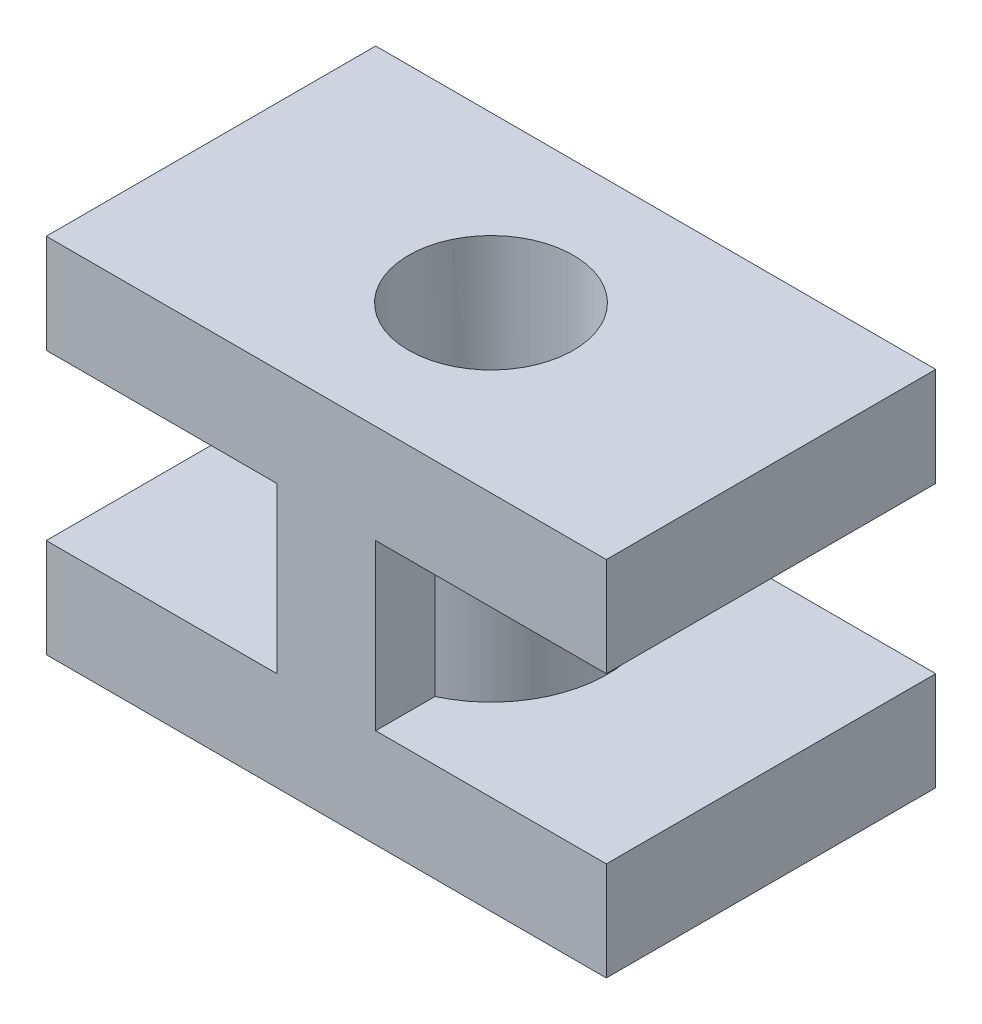
from build123d import *

# Parameters (mm, degrees)
SKETCH1_W           = 8.5
SKETCH1_H           = 5
BOSS_EXTRUDE1_DEPTH = 1.5
BOSS_EXTRUDE2_DEPTH = 2.5
SKETCH3_W           = 8.5
SKETCH3_H           = 5
BOSS_EXTRUDE3_DEPTH = 1.5
SKETCH4_R           = 1.25
CUT_EXTRUDE1_DEPTH  = 11.5


with BuildPart() as part:
    # Sketch1 → Boss-Extrude1 (new body)
    with BuildSketch(Plane(origin=(0, 0, 0), x_dir=(1, 0, 0), z_dir=(0, 1, 0))):
        Rectangle(SKETCH1_W, SKETCH1_H)
    extrude(amount=BOSS_EXTRUDE1_DEPTH)

    # Sketch2 → Boss-Extrude2 (add)
    with BuildSketch(Plane(origin=(0, 1.5, 0), x_dir=(1, 0, 0), z_dir=(0, 1, 0))):
        with BuildLine():
            Line((-0.75, -2.5), (0.75, -2.5))
            Line((0.75, -2.5), (0.75, -1.600781056))
            ThreePointArc((0.75, -1.600781056), (0, 1.76776695), (-0.75, -1.600781056))
            Line((-0.75, -1.600781056), (-0.75, -2.5))
        make_face()
    extrude(amount=BOSS_EXTRUDE2_DEPTH)

    # Sketch3 → Boss-Extrude3 (add)
    with BuildSketch(Plane(origin=(0, 4, 0), x_dir=(1, 0, 0), z_dir=(0, 1, 0))):
        Rectangle(SKETCH3_W, SKETCH3_H)
    extrude(amount=BOSS_EXTRUDE3_DEPTH)

    # Sketch4 → Cut-Extrude1 (cut)
    with BuildSketch(Plane(origin=(0, 5.5, 0), x_dir=(1, 0, 0), z_dir=(0, 1, 0))):
        Circle(SKETCH4_R)
    extrude(amount=-CUT_EXTRUDE1_DEPTH, mode=Mode.SUBTRACT)


solid = part.part
